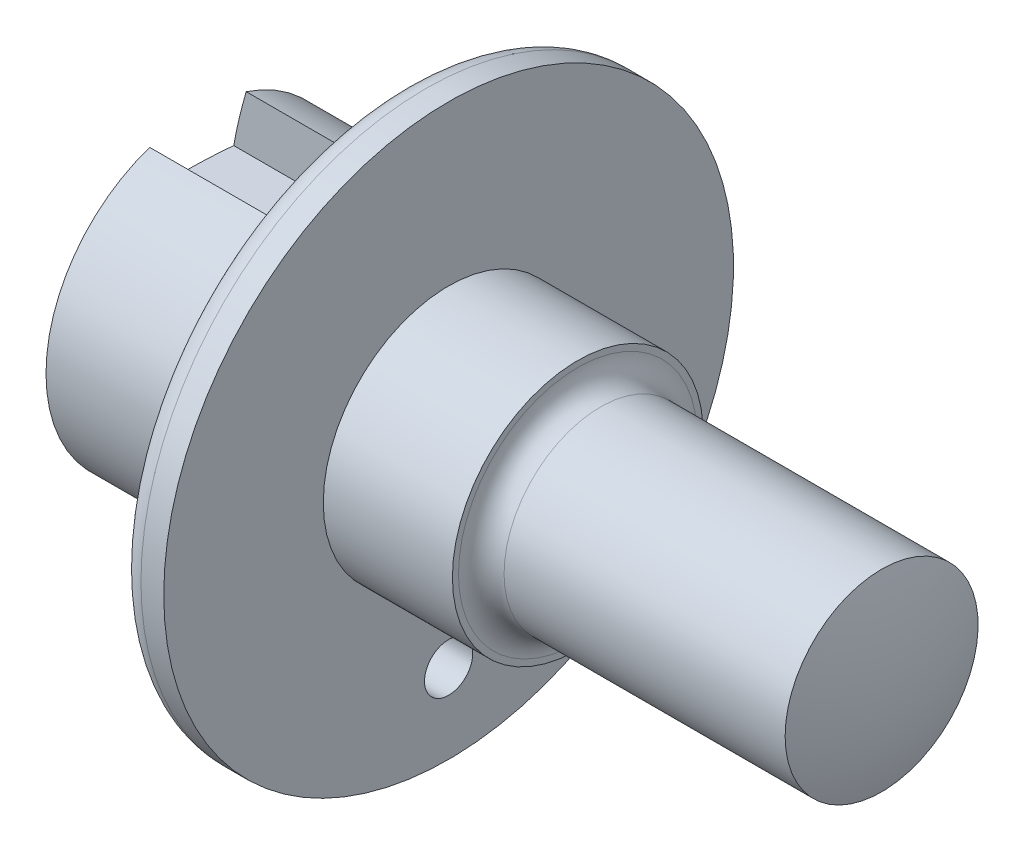
from build123d import *

# Parameters (mm, degrees)
FILETE1_R             = 3
ESBO_O2_W             = 12.7
ESBO_O2_H             = 16
CORTE_EXTRUS_O1_DEPTH = 20
ESBO_O3_R             = 3.175
CORTE_EXTRUS_O2_DEPTH = 20


with BuildPart() as part:
    # Esboço1 → Revolução1 (revolve)
    with BuildSketch(Plane.XY, mode=Mode.PRIVATE) as revolu_o1_sk:
        with BuildLine():
            Line((45.5, 12.7), (8.5, 12.7))
            ThreePointArc((8.5, 12.7), (6.378679656, 13.578679656), (5.5, 15.7))
            Line((5.5, 15.7), (5.5, 16.5))
            Line((5.5, 16.5), (-11.5, 16.5))
            Line((-11.5, 16.5), (-11.5, 37.5))
            Line((-11.5, 37.5), (-17.5, 37.5))
            Line((-17.5, 37.5), (-17.5, 20))
            Line((-17.5, 20), (-44.5, 20))
            ThreePointArc((-44.5, 20), (-46.745828054, 10.111874208), (-47.5, 0))
            Line((-47.5, 0), (47.5, 0))
            ThreePointArc((47.5, 0), (46.996937848, 6.428257929), (45.5, 12.7))
        make_face()
    revolve(revolu_o1_sk.sketch.rotate(Axis((-47.5, 0, 0), (1, 0, 0)), 90), axis=Axis((-47.5, 0, 0), (1, 0, 0)))  # turned: the seam where the file's is

    # Filete1
    filete1_edges = [part.edges().sort_by_distance(p)[0] for p in [
        (-17.5, 0, -37.5),
    ]]
    fillet(filete1_edges, radius=FILETE1_R)

    # Esboço2 → Corte-extrusão1 (cut)
    with BuildSketch(Plane.ZY.offset(47.5)):
        with Locations((0, 20)):
            Rectangle(ESBO_O2_W, ESBO_O2_H)
    extrude(amount=-CORTE_EXTRUS_O1_DEPTH, mode=Mode.SUBTRACT)

    # Esboço3 → Corte-extrusão2 (cut)
    with BuildSketch(Plane.ZY.offset(17.5)):
        with Locations((0, -27)):
            Circle(ESBO_O3_R)
    extrude(amount=-CORTE_EXTRUS_O2_DEPTH, mode=Mode.SUBTRACT)


solid = part.part
